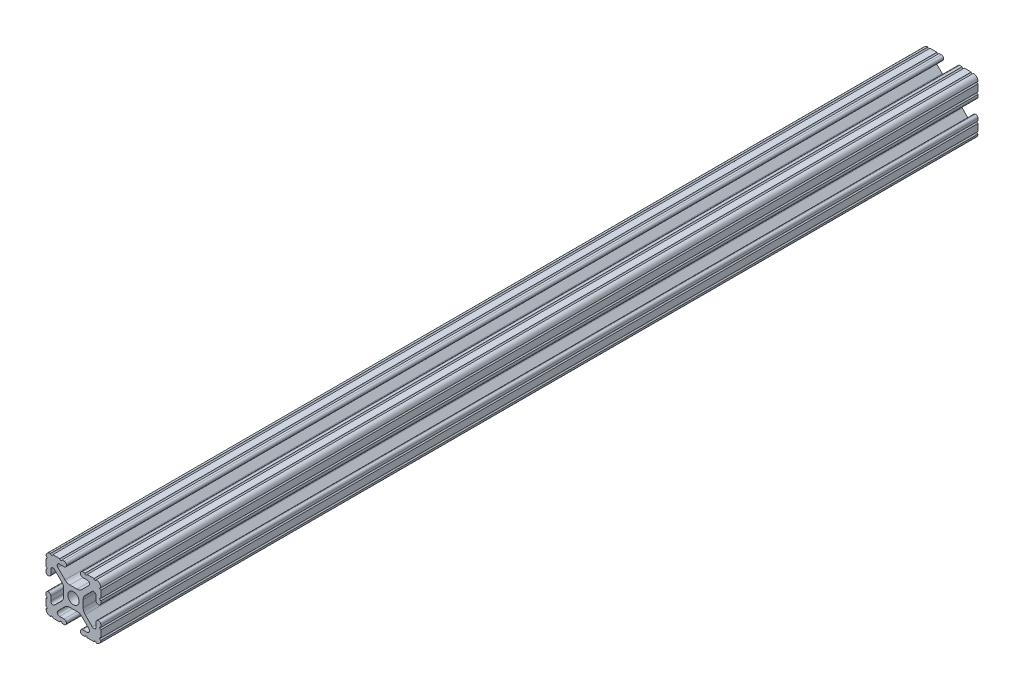
from build123d import *

# Parameters (mm, degrees)
SKETCH1_R      = 2.6035
EXTRUDE1_DEPTH = 406.4


with BuildPart() as part:
    # Sketch1 → Extrude1 (new body)
    with BuildSketch(Plane.XY):
        with BuildLine():
            Line((-7.207036008, 8.724370562), (-3.898272566, 5.423169045))
            ThreePointArc((-3.898272566, 5.423169045), (-2.869120213, 4.736787962), (-1.655778399, 4.4958))
            Line((-1.655778399, 4.4958), (1.655778399, 4.4958))
            ThreePointArc((1.655778399, 4.4958), (2.869120213, 4.736787962), (3.898272566, 5.423169045))
            Line((3.898272566, 5.423169045), (7.207036008, 8.724370562))
            ThreePointArc((7.207036008, 8.724370562), (7.432222385, 9.85140422), (6.476788598, 10.4902))
            Line((6.476788598, 10.4902), (4.287512407, 10.4902))
            ThreePointArc((4.287512407, 10.4902), (3.54574862, 10.79744862), (3.2385, 11.539212407))
            Line((3.2385, 11.539212407), (3.2385, 11.650987593))
            ThreePointArc((3.2385, 11.650987593), (3.54574862, 12.39275138), (4.287512407, 12.7))
            Line((4.287512407, 12.7), (5.317126718, 12.7))
            ThreePointArc((5.317126718, 12.7), (5.825126718, 12.192), (6.333126718, 12.7))
            Line((6.333126718, 12.7), (9.550443118, 12.7))
            ThreePointArc((9.550443118, 12.7), (10.058366869, 12.192000006), (10.566443095, 12.699847501))
            ThreePointArc((10.566443095, 12.699847501), (12.082537762, 12.08250727), (12.699846982, 10.566399977))
            ThreePointArc((12.699846982, 10.566399977), (12.192000006, 10.058323491), (12.7, 9.5504))
            Line((12.7, 9.5504), (12.7, 6.3330836))
            ThreePointArc((12.7, 6.3330836), (12.192, 5.8250836), (12.7, 5.3170836))
            Line((12.7, 5.3170836), (12.7, 4.287469289))
            ThreePointArc((12.7, 4.287469289), (12.39275138, 3.545705502), (11.650987593, 3.238456882))
            Line((11.650987593, 3.238456882), (11.539212407, 3.238456882))
            ThreePointArc((11.539212407, 3.238456882), (10.79744862, 3.545705502), (10.4902, 4.287469289))
            Line((10.4902, 4.287469289), (10.4902, 6.402089023))
            ThreePointArc((10.4902, 6.402089023), (9.856505071, 7.351067942), (8.737131347, 7.129408934))
            Line((8.737131347, 7.129408934), (5.441005833, 3.840816462))
            ThreePointArc((5.441005833, 3.840816462), (4.750877967, 2.809883091), (4.5085, 1.593185507))
            Line((4.5085, 1.593185507), (4.5085, -1.593185507))
            ThreePointArc((4.5085, -1.593185507), (4.750877967, -2.809883091), (5.441005833, -3.840816462))
            Line((5.441005833, -3.840816462), (8.737131347, -7.129408934))
            ThreePointArc((8.737131347, -7.129408934), (9.856505071, -7.351067942), (10.4902, -6.402089023))
            Line((10.4902, -6.402089023), (10.4902, -4.287469289))
            ThreePointArc((10.4902, -4.287469289), (10.79744862, -3.545705502), (11.539212407, -3.238456882))
            Line((11.539212407, -3.238456882), (11.650987593, -3.238456882))
            ThreePointArc((11.650987593, -3.238456882), (12.39275138, -3.545705502), (12.7, -4.287469289))
            Line((12.7, -4.287469289), (12.7, -5.3170836))
            ThreePointArc((12.7, -5.3170836), (12.192, -5.8250836), (12.7, -6.3330836))
            Line((12.7, -6.3330836), (12.7, -9.5504))
            ThreePointArc((12.7, -9.5504), (12.192000006, -10.058323491), (12.699846982, -10.566399977))
            ThreePointArc((12.699846982, -10.566399977), (12.082537762, -12.08250727), (10.566443095, -12.699847501))
            ThreePointArc((10.566443095, -12.699847501), (10.058366869, -12.192000006), (9.550443118, -12.7))
            Line((9.550443118, -12.7), (6.333126718, -12.7))
            ThreePointArc((6.333126718, -12.7), (5.825126718, -12.192), (5.317126718, -12.7))
            Line((5.317126718, -12.7), (4.287512407, -12.7))
            ThreePointArc((4.287512407, -12.7), (3.54574862, -12.39275138), (3.2385, -11.650987593))
            Line((3.2385, -11.650987593), (3.2385, -11.539212407))
            ThreePointArc((3.2385, -11.539212407), (3.54574862, -10.79744862), (4.287512407, -10.4902))
            Line((4.287512407, -10.4902), (6.416408329, -10.4902))
            ThreePointArc((6.416408329, -10.4902), (7.41473083, -9.822813117), (7.179650497, -8.645192506))
            Line((7.179650497, -8.645192506), (3.952270251, -5.423690499))
            ThreePointArc((3.952270251, -5.423690499), (2.922936451, -4.736929036), (1.709253557, -4.4958))
            Line((1.709253557, -4.4958), (-1.709253557, -4.4958))
            ThreePointArc((-1.709253557, -4.4958), (-2.922936451, -4.736929036), (-3.952270251, -5.423690499))
            Line((-3.952270251, -5.423690499), (-7.179650497, -8.645192506))
            ThreePointArc((-7.179650497, -8.645192506), (-7.41473083, -9.822813117), (-6.416408329, -10.4902))
            Line((-6.416408329, -10.4902), (-4.287512407, -10.4902))
            ThreePointArc((-4.287512407, -10.4902), (-3.54574862, -10.79744862), (-3.2385, -11.539212407))
            Line((-3.2385, -11.539212407), (-3.2385, -11.650987593))
            ThreePointArc((-3.2385, -11.650987593), (-3.54574862, -12.39275138), (-4.287512407, -12.7))
            Line((-4.287512407, -12.7), (-5.317126718, -12.7))
            ThreePointArc((-5.317126718, -12.7), (-5.825126718, -12.192), (-6.333126718, -12.7))
            Line((-6.333126718, -12.7), (-9.550443118, -12.7))
            ThreePointArc((-9.550443118, -12.7), (-10.058366869, -12.192000006), (-10.566443095, -12.699847501))
            ThreePointArc((-10.566443095, -12.699847501), (-12.082537762, -12.08250727), (-12.699846982, -10.566399977))
            ThreePointArc((-12.699846982, -10.566399977), (-12.192000006, -10.058323491), (-12.7, -9.5504))
            Line((-12.7, -9.5504), (-12.7, -6.3330836))
            ThreePointArc((-12.7, -6.3330836), (-12.192, -5.8250836), (-12.7, -5.3170836))
            Line((-12.7, -5.3170836), (-12.7, -4.287469289))
            ThreePointArc((-12.7, -4.287469289), (-12.39275138, -3.545705502), (-11.650987593, -3.238456882))
            Line((-11.650987593, -3.238456882), (-11.539212407, -3.238456882))
            ThreePointArc((-11.539212407, -3.238456882), (-10.79744862, -3.545705502), (-10.4902, -4.287469289))
            Line((-10.4902, -4.287469289), (-10.4902, -6.402089023))
            ThreePointArc((-10.4902, -6.402089023), (-9.856505071, -7.351067942), (-8.737131347, -7.129408934))
            Line((-8.737131347, -7.129408934), (-5.441005833, -3.840816462))
            ThreePointArc((-5.441005833, -3.840816462), (-4.750877967, -2.809883091), (-4.5085, -1.593185507))
            Line((-4.5085, -1.593185507), (-4.5085, 1.593185507))
            ThreePointArc((-4.5085, 1.593185507), (-4.750877967, 2.809883091), (-5.441005833, 3.840816462))
            Line((-5.441005833, 3.840816462), (-8.737131347, 7.129408934))
            ThreePointArc((-8.737131347, 7.129408934), (-9.856505071, 7.351067942), (-10.4902, 6.402089023))
            Line((-10.4902, 6.402089023), (-10.4902, 4.287469289))
            ThreePointArc((-10.4902, 4.287469289), (-10.79744862, 3.545705502), (-11.539212407, 3.238456882))
            Line((-11.539212407, 3.238456882), (-11.650987593, 3.238456882))
            ThreePointArc((-11.650987593, 3.238456882), (-12.39275138, 3.545705502), (-12.7, 4.287469289))
            Line((-12.7, 4.287469289), (-12.7, 5.3170836))
            ThreePointArc((-12.7, 5.3170836), (-12.192, 5.8250836), (-12.7, 6.3330836))
            Line((-12.7, 6.3330836), (-12.7, 9.5504))
            ThreePointArc((-12.7, 9.5504), (-12.192000006, 10.058323491), (-12.699846982, 10.566399977))
            ThreePointArc((-12.699846982, 10.566399977), (-12.082537762, 12.08250727), (-10.566443095, 12.699847501))
            ThreePointArc((-10.566443095, 12.699847501), (-10.058366869, 12.192000006), (-9.550443118, 12.7))
            Line((-9.550443118, 12.7), (-6.333126718, 12.7))
            ThreePointArc((-6.333126718, 12.7), (-5.825126718, 12.192), (-5.317126718, 12.7))
            Line((-5.317126718, 12.7), (-4.287512407, 12.7))
            ThreePointArc((-4.287512407, 12.7), (-3.54574862, 12.39275138), (-3.2385, 11.650987593))
            Line((-3.2385, 11.650987593), (-3.2385, 11.539212407))
            ThreePointArc((-3.2385, 11.539212407), (-3.54574862, 10.79744862), (-4.287512407, 10.4902))
            Line((-4.287512407, 10.4902), (-6.476788598, 10.4902))
            ThreePointArc((-6.476788598, 10.4902), (-7.432222385, 9.85140422), (-7.207036008, 8.724370562))
        make_face()
        Circle(SKETCH1_R, mode=Mode.SUBTRACT)
    extrude(amount=-EXTRUDE1_DEPTH)


solid = part.part
